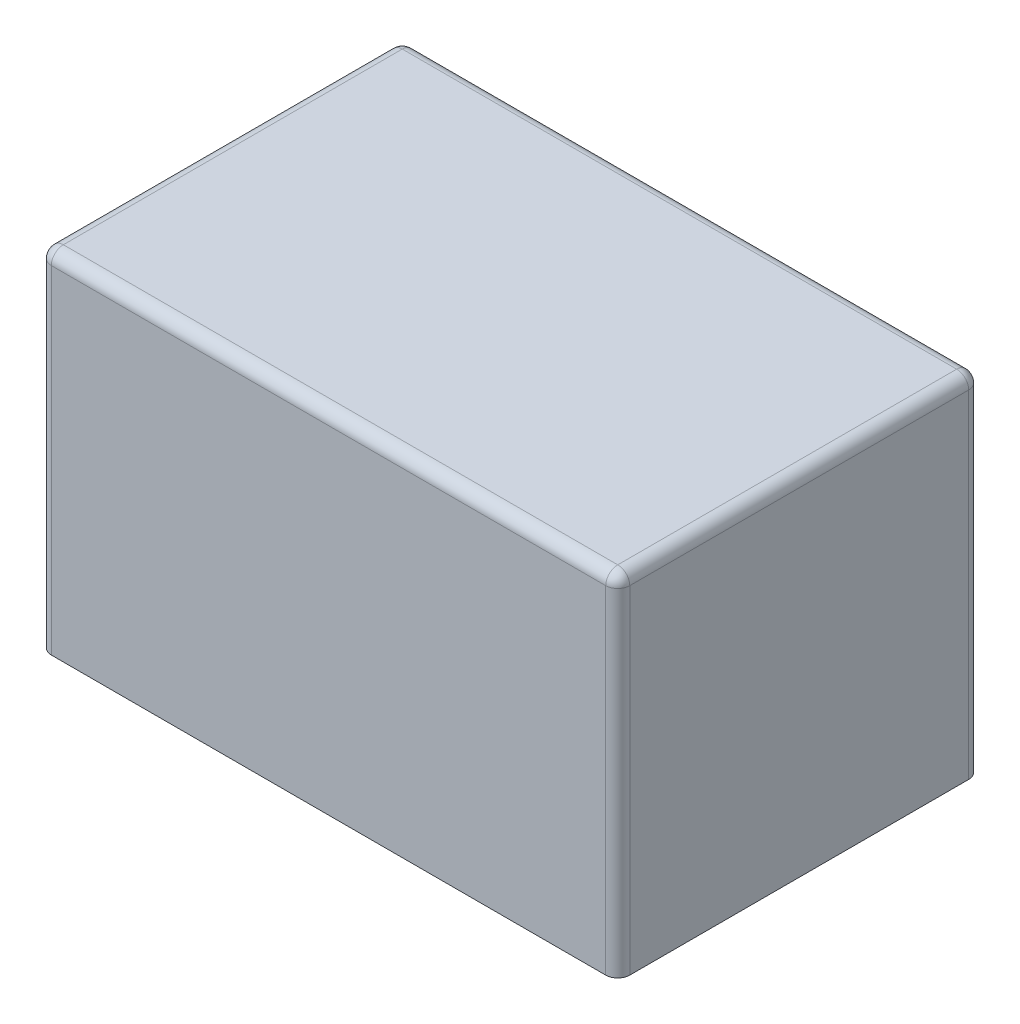
from build123d import *

# Parameters (mm, degrees)
SKETCH1_W           = 15.3
SKETCH1_H           = 9.6
BOSS_EXTRUDE1_DEPTH = 9.24
FILLET1_R           = 0.318


with BuildPart() as part:
    # Sketch1 → Boss-Extrude1 (new body)
    with BuildSketch(Plane(origin=(0, 0, 0), x_dir=(1, 0, 0), z_dir=(0, 1, 0))):
        Rectangle(SKETCH1_W, SKETCH1_H)
    extrude(amount=BOSS_EXTRUDE1_DEPTH)

    # Fillet1
    fillet1_edges = [part.edges().sort_by_distance(p)[0] for p in [
        (7.65, 9.24, 0),
        (0, 9.24, -4.8),
        (-7.65, 9.24, 0),
        (0, 9.24, 4.8),
        (-7.65, 4.62, -4.8),
        (7.65, 4.62, -4.8),
        (7.65, 4.62, 4.8),
        (-7.65, 4.62, 4.8),
    ]]
    fillet(fillet1_edges, radius=FILLET1_R)


solid = part.part
